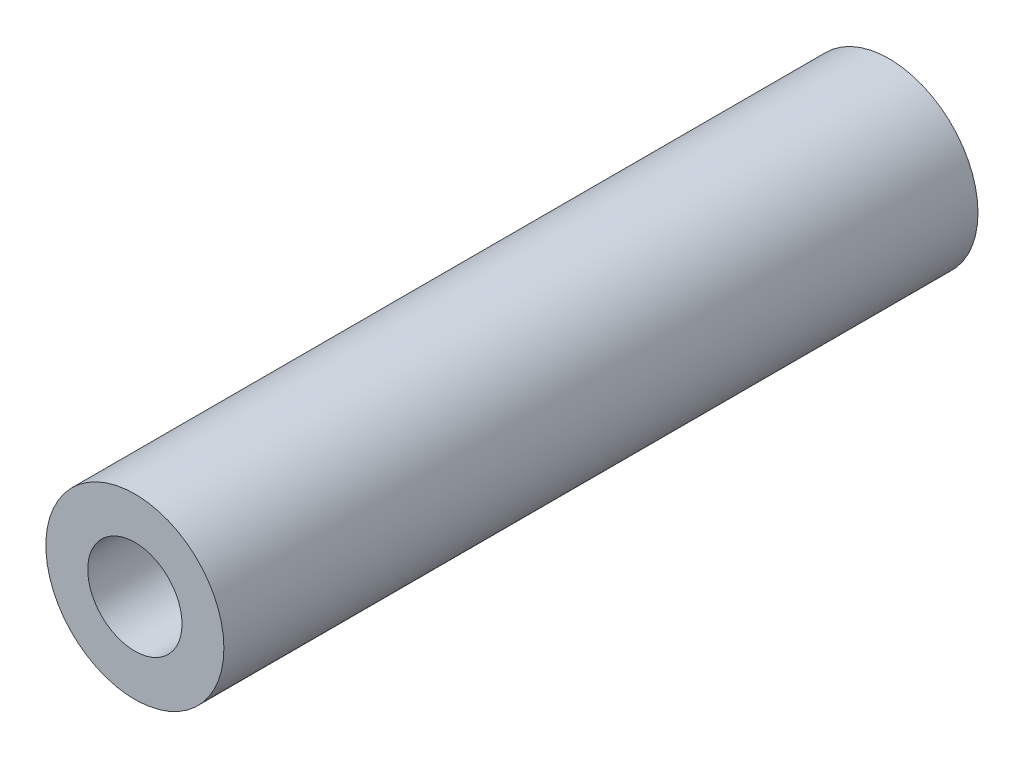
from build123d import *

# Parameters (mm, degrees)
SKETCH_1_R      = 4.25
SKETCH_1_R_2    = 2.25
EXTRUDE_1_DEPTH = 36


with BuildPart() as part:
    # 草图1 → 凸台-拉伸1 (new body)
    with BuildSketch(Plane.XY):
        Circle(SKETCH_1_R)
        Circle(SKETCH_1_R_2, mode=Mode.SUBTRACT)
    extrude(amount=EXTRUDE_1_DEPTH)


solid = part.part
